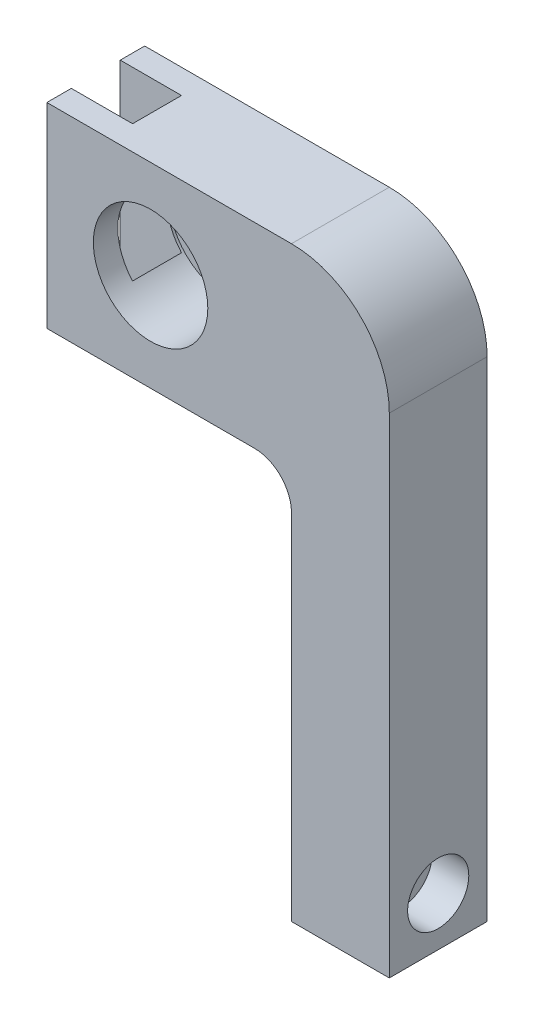
from build123d import *

# Parameters (mm, degrees)
BOSS_EXTRUDE1_DEPTH                                 = 12.7
SKETCH2_W                                           = 15.9004
SKETCH2_H                                           = 12.7
CUT_EXTRUDE1_DEPTH                                  = 1
CUT_EXTRUDE1_DEPTH_BACK                             = 153.4
CBORE_FOR_00_BINDING_HEAD_MACHINE_SCREW_D           = 12.7
CBORE_FOR_00_BINDING_HEAD_MACHINE_SCREW_CBORE_D     = 29.718
CBORE_FOR_00_BINDING_HEAD_MACHINE_SCREW_CBORE_DEPTH = 19.7104
LPATTERN1_COUNT                                     = 2
LPATTERN1_PITCH                                     = 44.45
LPATTERN1_COUNT_DIR2                                = 2
LPATTERN1_PITCH_DIR2                                = 19.05


with BuildPart() as part:
    # Sketch1 → Boss-Extrude1 (new body, symmetric)
    with BuildSketch(Plane.XY):
        with BuildLine():
            Line((0, 0), (0, 127))
            ThreePointArc((0, 127), (-7.439487758, 144.960512242), (-25.4, 152.4))
            Line((-25.4, 152.4), (-88.9, 152.4))
            Line((-88.9, 152.4), (-88.9, 101.6))
            Line((-88.9, 101.6), (-35.052, 101.6))
            ThreePointArc((-35.052, 101.6), (-28.227005348, 98.772994652), (-25.4, 91.948))
            Line((-25.4, 91.948), (-25.4, 0))
            Line((-25.4, 0), (0, 0))
        make_face()
    extrude(amount=BOSS_EXTRUDE1_DEPTH, both=True)

    # Sketch2 → Cut-Extrude1 (cut, two sides)
    with BuildSketch(Plane(origin=(0, 152.4, 0), x_dir=(1, 0, 0), z_dir=(0, 1, 0))) as cut_extrude1_sk:
        with Locations((-80.9498, 0)):
            Rectangle(SKETCH2_W, SKETCH2_H)
    extrude(amount=CUT_EXTRUDE1_DEPTH, mode=Mode.SUBTRACT)
    extrude(cut_extrude1_sk.sketch, amount=-CUT_EXTRUDE1_DEPTH_BACK, mode=Mode.SUBTRACT)

    # CBORE for #00 Binding Head Machine Screw1 (through all)
    with Locations(Plane.XY.offset(12.7)):
        with Locations((-61.976, 127)):
            CounterBoreHole(CBORE_FOR_00_BINDING_HEAD_MACHINE_SCREW_D / 2, CBORE_FOR_00_BINDING_HEAD_MACHINE_SCREW_CBORE_D / 2, CBORE_FOR_00_BINDING_HEAD_MACHINE_SCREW_CBORE_DEPTH)

    # Sketch7 → CBORE for 3/8 Socket Head Cap Screw1 (revolve, cut)
    with BuildSketch(Plane(origin=(0, 12.7, 0), x_dir=(0, 0, -1), z_dir=(0, 1, 0))):
        Polygon((0, 0), (0, 88.9), (5.0419, 88.9), (5.0419, 9.700511387), (5.334, 9.525), (7.9375, 9.525), (7.9375, 0), align=None)
    revolve(axis=Axis((6.35, 12.7, 0), (-1, 0, 0)), mode=Mode.SUBTRACT)

    # Sketch9 → #8-32 Tapped Hole1 (revolve, cut)
    with BuildSketch(Plane(origin=(-88.9, 104.775, -9.525), x_dir=(0, 0, 1), z_dir=(0, 1, 0))):
        Polygon((0, 0), (0, 9.927806461), (1.7272, 8.89), (1.7272, 0), align=None)
    f_8_32_tapped_hole1 = revolve(axis=Axis((-95.25, 104.775, -9.525), (1, 0, 0)), mode=Mode.SUBTRACT)

    # LPattern1: 8-32 Tapped Hole1 2 × 2
    with Locations(*[(0, i * LPATTERN1_PITCH, j * LPATTERN1_PITCH_DIR2) for i in range(LPATTERN1_COUNT) for j in range(LPATTERN1_COUNT_DIR2) if (i, j) != (0, 0)]):
        add(f_8_32_tapped_hole1, mode=Mode.SUBTRACT)


solid = part.part
